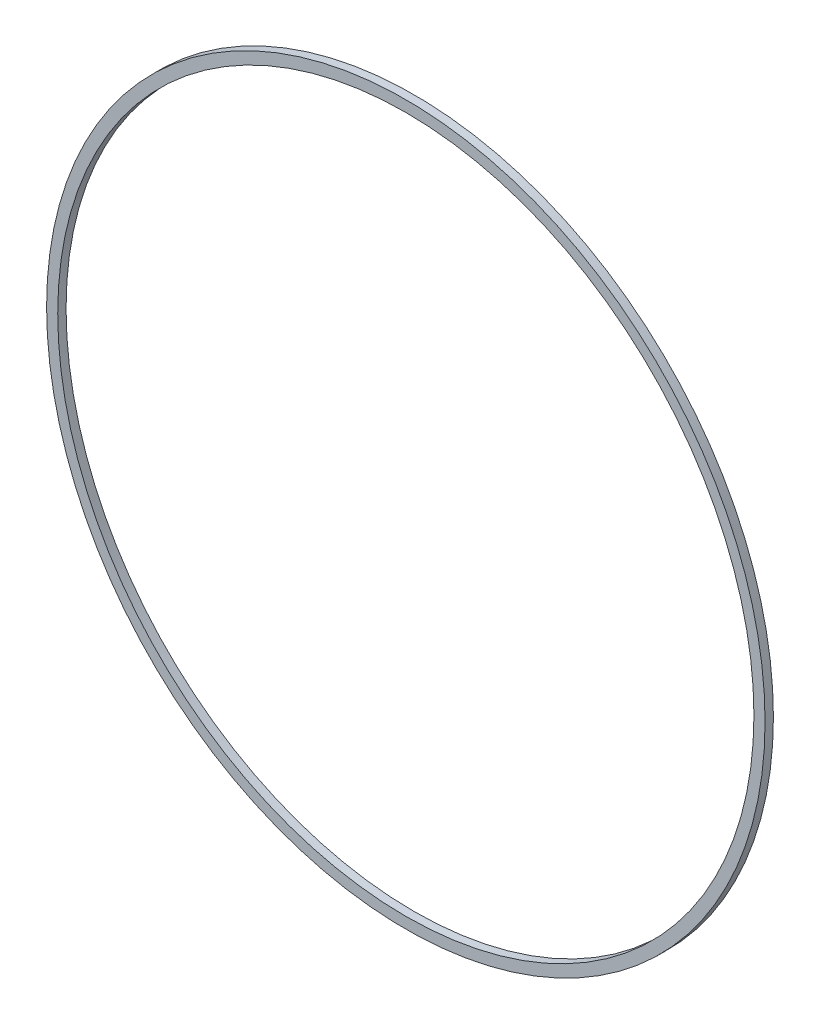
from build123d import *

# Parameters (mm, degrees)
CROQUIS1_R              = 258
CROQUIS1_R_2            = 250
SALIENTE_EXTRUIR1_DEPTH = 6


with BuildPart() as part:
    # Croquis1 → Saliente-Extruir1 (new body)
    with BuildSketch(Plane.XY):
        Circle(CROQUIS1_R)
        Circle(CROQUIS1_R_2, mode=Mode.SUBTRACT)
    extrude(amount=SALIENTE_EXTRUIR1_DEPTH)


solid = part.part
